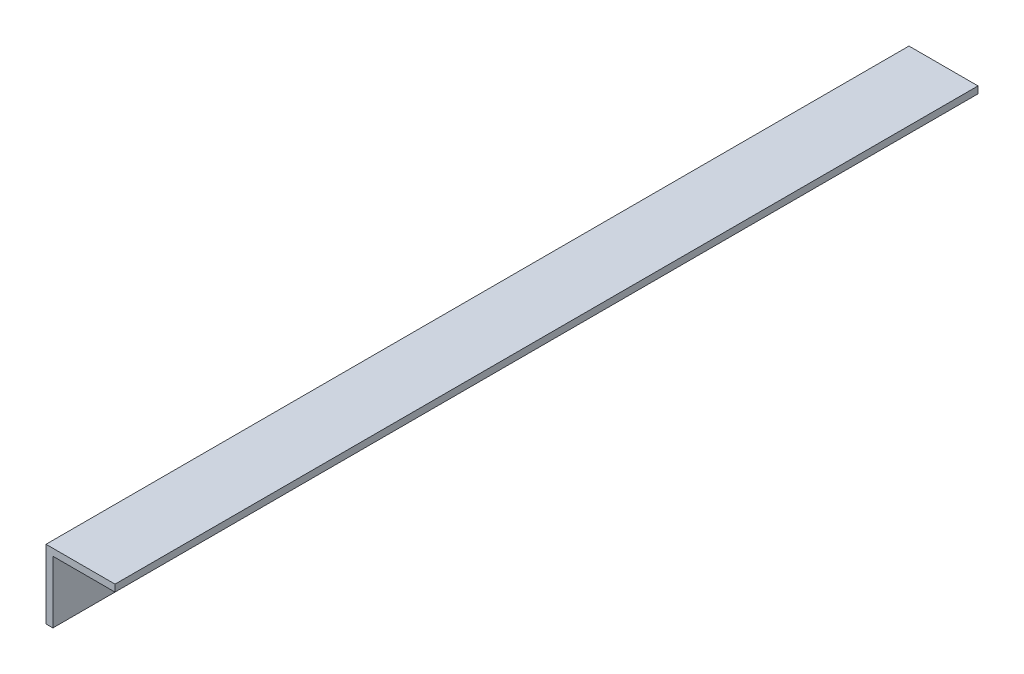
from build123d import *

# Parameters (mm, degrees)
BOSS_EXTRUDE1_DEPTH = 500


with BuildPart() as part:
    # Sketch1 → Boss-Extrude1 (new body)
    with BuildSketch(Plane.XY):
        Polygon((0, 0), (0, 40), (40, 40), (40, 36), (4, 36), (4, 0), align=None)
    extrude(amount=BOSS_EXTRUDE1_DEPTH)


solid = part.part
